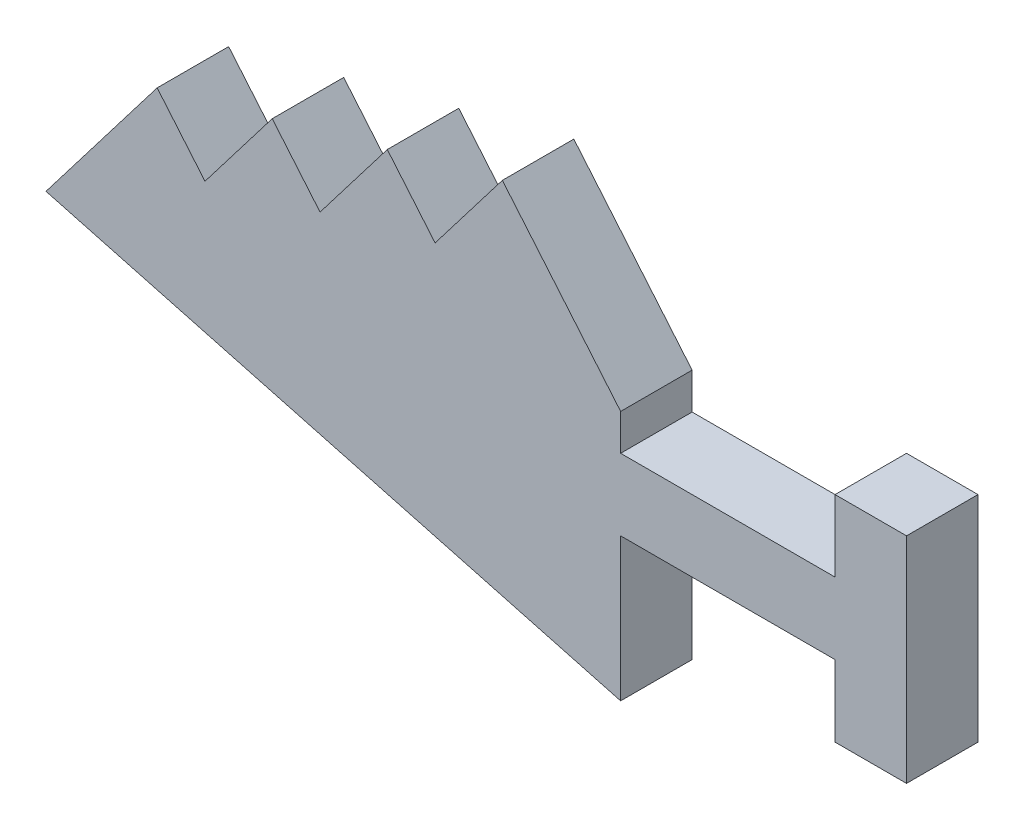
from build123d import *

# Parameters (mm, degrees)
BOSS_EXTRUDE1_DEPTH = 6


with BuildPart() as part:
    # Model → Boss-Extrude1 (new body)
    with BuildSketch(Plane.XY):
        Polygon((50.457183662, 33.098566994), (56.101816137, 40.471202151), (66.031945882, 28.636934351), (66.031945882, 25.591705494), (84.031945882, 25.591705494), (84.031945882, 31.591705494), (90.031945882, 31.591705494), (90.031945882, 13.591705494), (84.031945882, 13.591705494), (84.031945882, 19.591705494), (66.031945882, 19.591705494), (66.031945882, 7.591705494), (17.791877488, 20.517592863), (19.197870672, 22.354005565), (27.124041348, 32.706630797), (31.138667136, 27.922186092), (36.783299611, 35.294821248), (40.797925399, 30.510376543), (46.442557874, 37.883011699), align=None)
    extrude(amount=BOSS_EXTRUDE1_DEPTH)


solid = part.part
